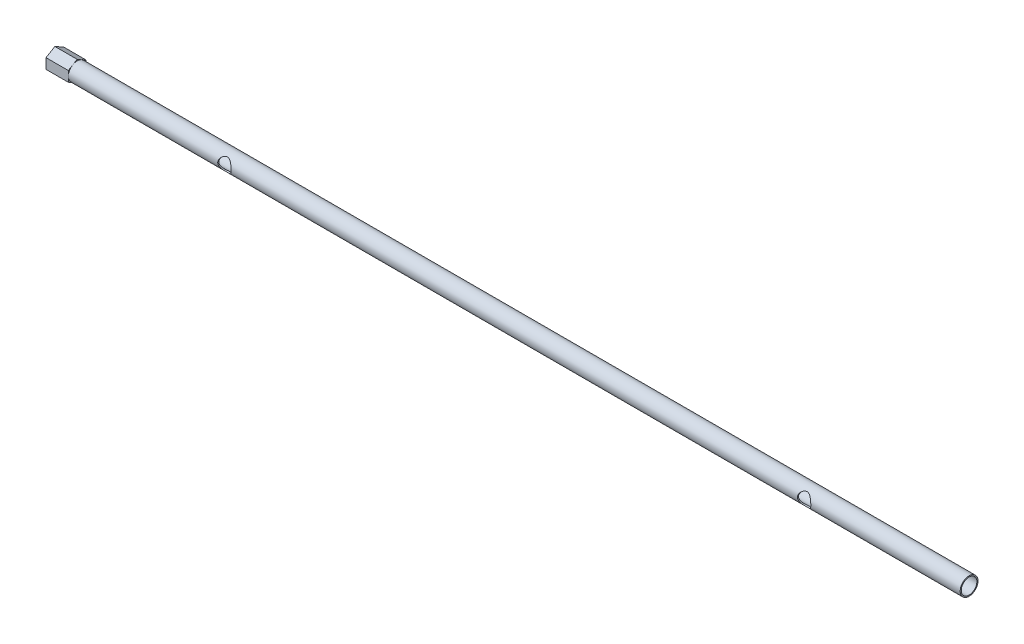
from build123d import *

# Parameters (mm, degrees)
SWEEP1_PROFILE_R    = 2
BOSS_EXTRUDE1_DEPTH = 5
SKETCH10_R          = 1.75
CUT_EXTRUDE1_DEPTH  = 200
CUT_EXTRUDE3_REACH  = 6.012
SKETCH35_R          = 1.5


with BuildPart() as part:
    # Sweep1: sweep along a path in Sketch2
    with BuildLine(Plane(origin=(0, 0, 0), x_dir=(1, 0, 0), z_dir=(0, 1, 0))) as sweep1_path:
        Line((-100, 0), (100, 0))
    # Sweep1 profile (on start of the path) → Sweep1 (sweep)
    with BuildSketch(Plane(origin=(-100, 0, 0), x_dir=(0, 0, 1), z_dir=(1, 0, 0))):
        Circle(SWEEP1_PROFILE_R)
    sweep(path=sweep1_path.line)

    # Sketch9 → Boss-Extrude1 (add)
    with BuildSketch(Plane.ZY.offset(100)):
        Polygon((1.98826653, -1.174789146), (2.01153051, 1.134494752), (0.023263979, 2.309283898), (-1.98826653, 1.174789146), (-2.01153051, -1.134494752), (-0.023263979, -2.309283898), align=None)
    extrude(amount=BOSS_EXTRUDE1_DEPTH)

    # Sketch10 → Cut-Extrude1 (cut)
    with BuildSketch(Plane(origin=(100, 0, 0), x_dir=(0, 0, -1), z_dir=(1, 0, 0))):
        Circle(SKETCH10_R)
    extrude(amount=-CUT_EXTRUDE1_DEPTH, mode=Mode.SUBTRACT)

    # Sketch35 → Cut-Extrude3 (cut, up to next)
    with BuildSketch(Plane.XY.offset(2), mode=Mode.PRIVATE) as cut_extrude3_sk1:
        with Locations((65, 0)):
            Circle(SKETCH35_R)
    cut_extrude3_tool1 = extrude(cut_extrude3_sk1.sketch, amount=-CUT_EXTRUDE3_REACH, mode=Mode.PRIVATE) & part.part
    add(cut_extrude3_tool1.solids().sort_by_distance((65, 0, 2))[0], mode=Mode.SUBTRACT)
    # Sketch35 → Cut-Extrude3 (cut, up to next)
    with BuildSketch(Plane.XY.offset(2), mode=Mode.PRIVATE) as cut_extrude3_sk2:
        with Locations((-65, 0)):
            Circle(SKETCH35_R)
    cut_extrude3_tool2 = extrude(cut_extrude3_sk2.sketch, amount=-CUT_EXTRUDE3_REACH, mode=Mode.PRIVATE) & part.part
    add(cut_extrude3_tool2.solids().sort_by_distance((-65, 0, 2))[0], mode=Mode.SUBTRACT)


solid = part.part
